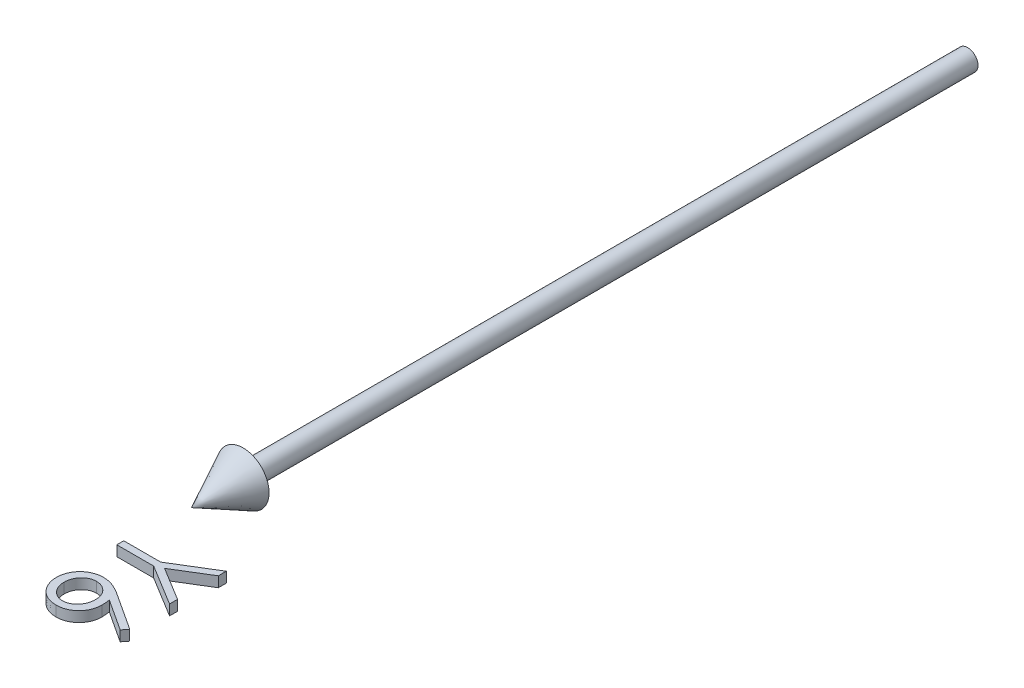
from build123d import *

# Parameters (mm, degrees)
BOSS_EXTRUDE1_DEPTH        = 1
BOSS_EXTRUDE1_DEPTH_BACK   = 1
BOSS_EXTRUDE1_2_DEPTH      = 1
BOSS_EXTRUDE1_2_DEPTH_BACK = 1


with BuildPart() as part:
    # Sketch2 → Revolve1 (revolve)
    with BuildSketch(Plane(origin=(0, 0, 0), x_dir=(1, 0, 0), z_dir=(0, 1, 0))):
        Polygon((0, -150), (5, -140), (2, -140), (2, 0), (0, 0), align=None)
    revolve(axis=Axis((0, 0, -41.949952025), (0, 0, 1)))


with BuildPart() as body_2:
    # Sketch3 → Boss-Extrude1 (new, two sides: drawn at the far end of the back side and taken through both)
    with BuildSketch(Plane(origin=(0, 0, 0), x_dir=(1, 0, 0), z_dir=(0, 1, 0)).offset(-BOSS_EXTRUDE1_DEPTH_BACK)):
        Polygon((15, -158.269230769), (15, -159.810697115), (8.5546875, -163.753004808), (15, -167.689302885), (15, -169.230769231), (7.130408654, -164.423076923), (0, -164.423076923), (0, -163.076923077), (7.130408654, -163.076923077), align=None)
    extrude(amount=BOSS_EXTRUDE1_DEPTH + BOSS_EXTRUDE1_DEPTH_BACK)


with BuildPart() as body_3:
    # Sketch3 → Boss-Extrude1 2 (new, two sides: drawn at the far end of the back side and taken through both)
    with BuildSketch(Plane(origin=(0, 0, 0), x_dir=(1, 0, 0), z_dir=(0, 1, 0)).offset(-BOSS_EXTRUDE1_2_DEPTH_BACK)):
        with BuildLine():
            Line((15.384615385, -177.307692308), (14.5703125, -178.344350962))
            Line((14.5703125, -178.344350962), (8.509615385, -174.381009615))
            add(Edge.make_bspline(
                [(8.509615385, -174.381009615), (8.551674787, -174.644882231), (8.633716408, -175.159595603), (8.64725046, -175.680592311), (8.653846154, -175.934495192)],
                knots=[0, 0, 0, 0, 1.025318673, 2, 2, 2, 2], degree=3))
            add(Edge.make_bspline(
                [(8.653846154, -175.934495192), (8.649748532, -176.086948748), (8.641682486, -176.387049036), (8.57960884, -176.827649616), (8.481786932, -177.251030771), (8.33919155, -177.65543768), (8.157038602, -178.042321888), (7.938729158, -178.413903586), (7.672990528, -178.763197915), (7.376140718, -179.094702969), (7.047353641, -179.395676243), (6.69849077, -179.662145053), (6.329915565, -179.88597416), (5.941814711, -180.067576681), (5.534786456, -180.20859759), (5.109351573, -180.311401783), (4.665216695, -180.372171466), (4.363167372, -180.380423569), (4.209735577, -180.384615385)],
                knots=[0, 0, 0, 0, 1.04369286, 2.054478336, 3.041073146, 4.015093852, 4.984733326, 5.965804835, 6.960378782, 7.985147595, 9.009457201, 10.008161701, 10.986880575, 11.956520048, 12.937015923, 13.931873656, 14.949455224, 16, 16, 16, 16], degree=3))
            add(Edge.make_bspline(
                [(4.209735577, -180.384615385), (3.999947344, -180.376787405), (3.587377155, -180.361392875), (2.983959664, -180.249327236), (2.413710712, -180.055926984), (1.874389314, -179.797180637), (1.38168706, -179.461477597), (0.936416339, -179.063651039), (0.548297495, -178.599940388), (0.215346507, -178.081326416), (-0.049182634, -177.520025038), (-0.244754428, -176.931482182), (-0.361613545, -176.320728396), (-0.376912837, -175.905942541), (-0.384615385, -175.697115385)],
                knots=[0, 0, 0, 0, 1.031881447, 2.029301251, 3.006342947, 3.987068354, 4.962916383, 5.929513747, 6.915671209, 7.928552063, 8.953527267, 9.960179832, 10.973036711, 12, 12, 12, 12], degree=3))
            add(Edge.make_bspline(
                [(-0.384615385, -175.697115385), (-0.378065948, -175.495272343), (-0.365092661, -175.095456617), (-0.249524114, -174.50731664), (-0.062208875, -173.942187268), (0.195855766, -173.40404089), (0.5218053, -172.905493801), (0.914262334, -172.459609466), (1.364553117, -172.067939213), (1.874058975, -171.74370554), (2.418030387, -171.479454216), (2.990406475, -171.293073936), (3.579667942, -171.172541322), (3.980785131, -171.160105749), (4.182692308, -171.153846154)],
                knots=[0, 0, 0, 0, 1.011913813, 2.004424092, 2.994488568, 3.992479987, 4.990471406, 5.973328987, 6.963763268, 7.974390938, 8.994854117, 9.989689954, 10.988086187, 12, 12, 12, 12], degree=3))
            add(Edge.make_bspline(
                [(4.182692308, -171.153846154), (4.337112847, -171.159282361), (4.652269778, -171.170377118), (5.130964519, -171.236589347), (5.618852651, -171.358030666), (6.032448307, -171.489456716), (6.374980445, -171.61987103), (6.645469026, -171.740794184), (6.931113653, -171.876001003), (7.226509648, -172.034482224), (7.540097115, -172.202485108), (7.860262952, -172.398731542), (8.198700605, -172.60351771), (8.424027137, -172.753538837), (8.539663462, -172.830528846)],
                knots=[0, 0, 0, 0, 1.17367173, 2.395347028, 3.66355231, 4.98980831, 5.690886799, 6.447442954, 7.240630024, 8.091733897, 8.994365608, 9.943299771, 10.944512865, 12, 12, 12, 12], degree=3))
            Line((8.539663462, -172.830528846), (15.384615385, -177.307692308))
        make_face()
        with BuildLine():
            add(Edge.make_bspline(
                [(7.115384615, -175.652043269), (7.112005971, -175.537780091), (7.105377098, -175.313596676), (7.067937177, -174.985102114), (6.996998791, -174.675042777), (6.905238355, -174.379877282), (6.780300101, -174.102682029), (6.630338776, -173.840295042), (6.452044563, -173.595319963), (6.2474054, -173.372058978), (6.026627857, -173.167050253), (5.788738619, -172.990709272), (5.54100562, -172.838431661), (5.281100468, -172.714662654), (5.009189883, -172.618273871), (4.726506574, -172.548553542), (4.431159767, -172.50975155), (4.230877582, -172.5032963), (4.128605769, -172.5)],
                knots=[0, 0, 0, 0, 1.129474985, 2.216020618, 3.260639938, 4.268601163, 5.26556745, 6.258792394, 7.250684778, 8.252748164, 9.247500881, 10.223461414, 11.174097059, 12.117127289, 13.062595836, 14.020469732, 14.98917545, 16, 16, 16, 16], degree=3))
            add(Edge.make_bspline(
                [(4.128605769, -172.5), (4.027252571, -172.502691323), (3.828514037, -172.507968607), (3.535576783, -172.555665559), (3.25393368, -172.629043276), (2.983378733, -172.73644881), (2.725387777, -172.871166755), (2.478128225, -173.03695204), (2.241429415, -173.230997521), (2.021260049, -173.456571542), (1.819315357, -173.699831255), (1.639503424, -173.957094513), (1.488509482, -174.227543319), (1.369136869, -174.512720881), (1.271367854, -174.808634489), (1.202519363, -175.117541569), (1.163606496, -175.439713542), (1.157142303, -175.657950061), (1.153846154, -175.769230769)],
                knots=[0, 0, 0, 0, 0.989642335, 1.94054129, 2.892446913, 3.828371744, 4.778262963, 5.730973156, 6.732161388, 7.763274768, 8.805796303, 9.818398792, 10.825975928, 11.825728216, 12.834635236, 13.867465554, 14.912602056, 16, 16, 16, 16], degree=3))
            add(Edge.make_bspline(
                [(1.153846154, -175.769230769), (1.157142044, -175.880511659), (1.163605731, -176.098748537), (1.202522271, -176.420917918), (1.271357182, -176.729834578), (1.369175554, -177.025713366), (1.488365973, -177.311019461), (1.640449573, -177.581705003), (1.818222088, -177.841424442), (2.02160762, -178.084524569), (2.240185355, -178.311041427), (2.48027137, -178.500541938), (2.723422593, -178.671564756), (2.984406813, -178.801108562), (3.253770808, -178.909710259), (3.535620416, -178.982717754), (3.828502614, -179.030513411), (4.027248713, -179.035777132), (4.128605769, -179.038461538)],
                knots=[0, 0, 0, 0, 1.087205562, 2.132157158, 3.164804748, 4.173533273, 5.173108684, 6.180507559, 7.20098426, 8.243321352, 9.274252308, 10.269075238, 11.227079059, 12.172305571, 13.108064818, 14.05980203, 15.010532752, 16, 16, 16, 16], degree=3))
            add(Edge.make_bspline(
                [(4.128605769, -179.038461538), (4.231022874, -179.036130628), (4.432034342, -179.031555809), (4.726240478, -178.978810058), (5.011488565, -178.907568144), (5.281352931, -178.792434681), (5.543296409, -178.655301328), (5.78983246, -178.480602445), (6.027945494, -178.2803059), (6.248869632, -178.048343065), (6.450944828, -177.795988266), (6.629310054, -177.527627329), (6.7798468, -177.246881088), (6.905448365, -176.954020743), (6.99608905, -176.645694264), (7.06746007, -176.32687848), (7.105440152, -175.993496024), (7.112027573, -175.767310558), (7.115384615, -175.652043269)],
                knots=[0, 0, 0, 0, 0.978265087, 1.920016216, 2.851775529, 3.783928695, 4.718195979, 5.674835085, 6.667117013, 7.690134047, 8.732874136, 9.755756613, 10.767227014, 11.776017537, 12.797239016, 13.836276431, 14.897336092, 16, 16, 16, 16], degree=3))
        make_face(mode=Mode.SUBTRACT)
    extrude(amount=BOSS_EXTRUDE1_2_DEPTH + BOSS_EXTRUDE1_2_DEPTH_BACK)


solid = Compound([part.part, body_2.part, body_3.part])
